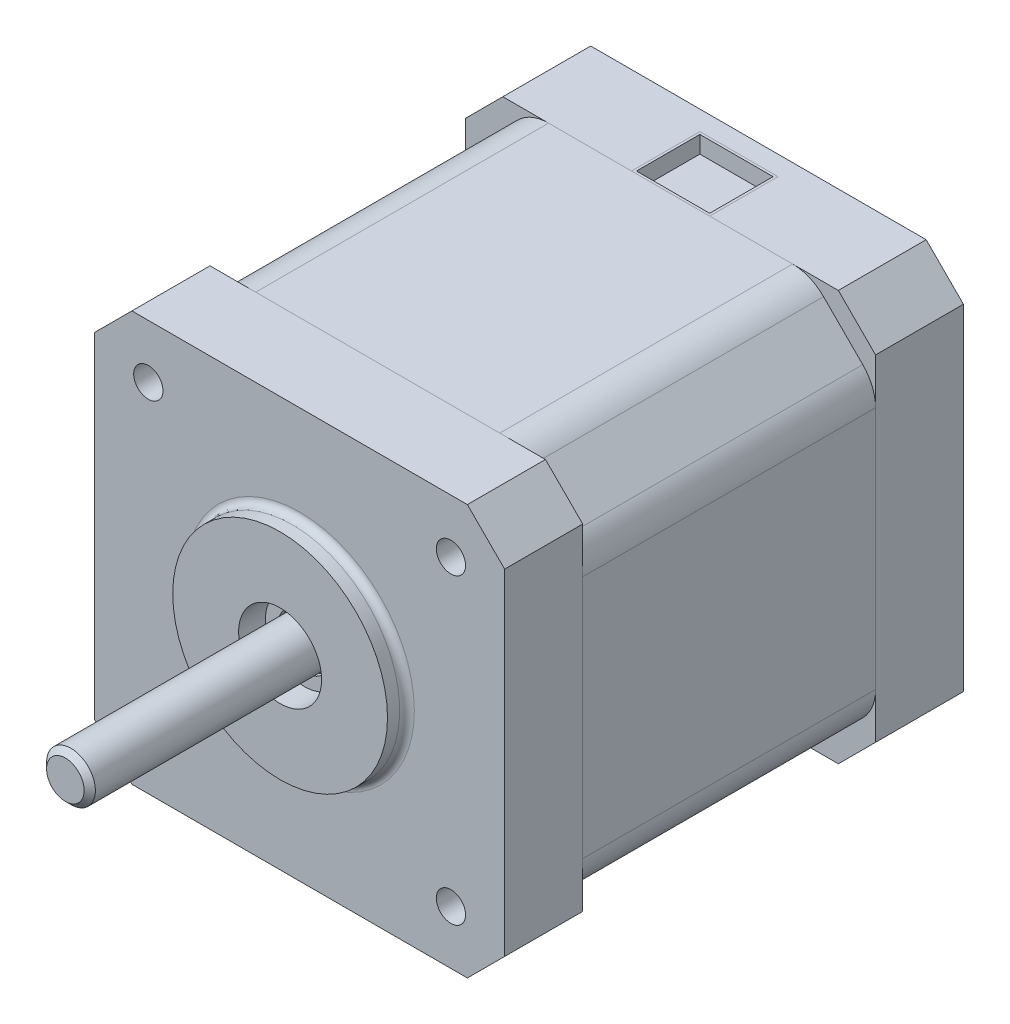
from build123d import *

# Parameters (mm, degrees)
BOSS_EXTRUDE1_DEPTH = 8
BOSS_EXTRUDE2_DEPTH = 30
BOSS_EXTRUDE3_DEPTH = 9
SKETCH5_R           = 1.5
CUT_EXTRUDE1_DEPTH  = 4.5
SKETCH6_R           = 11
BOSS_EXTRUDE4_DEPTH = 2
SKETCH9_R           = 4.25
CUT_EXTRUDE2_DEPTH  = 3
SKETCH8_R           = 2.5
BOSS_EXTRUDE5_DEPTH = 25
SKETCH11_R          = 4
SKETCH11_R_2        = 2.75
BOSS_EXTRUDE6_DEPTH = 0.5
FILLET1_R           = 0.75
SKETCH13_W          = 8
SKETCH13_H          = 7
CUT_EXTRUDE3_DEPTH  = 2
SKETCH14_W          = 8
SKETCH14_H          = 7
BOSS_EXTRUDE7_DEPTH = 0.25
SKETCH15_W          = 8
SKETCH15_H          = 7
SKETCH15_W_2        = 7.5
SKETCH15_H_2        = 6.5
BOSS_EXTRUDE8_DEPTH = 1.75


with BuildPart() as part:
    # Sketch1 → Boss-Extrude1 (new body)
    with BuildSketch(Plane.XY):
        Polygon((17.183766184, 21), (-17.183766184, 21), (-21, 17.183766184), (-21, -17.183766184), (-17.183766184, -21), (17.183766184, -21), (21, -17.183766184), (21, 17.183766184), align=None)
    extrude(amount=-BOSS_EXTRUDE1_DEPTH)

    # Sketch5 → Cut-Extrude1 (cut)
    with BuildSketch(Plane.XY):
        with Locations((-15.5, 15.5)):
            Circle(SKETCH5_R)
        with Locations((15.5, 15.5)):
            Circle(SKETCH5_R)
        with Locations((15.5, -15.5)):
            Circle(SKETCH5_R)
        with Locations((-15.5, -15.5)):
            Circle(SKETCH5_R)
    extrude(amount=-CUT_EXTRUDE1_DEPTH, mode=Mode.SUBTRACT)

    # Sketch6 → Boss-Extrude4 (add)
    with BuildSketch(Plane.XY):
        Circle(SKETCH6_R)
    extrude(amount=BOSS_EXTRUDE4_DEPTH)

    # Sketch9 → Cut-Extrude2 (cut)
    with BuildSketch(Plane.XY.offset(2)):
        Circle(SKETCH9_R)
    extrude(amount=-CUT_EXTRUDE2_DEPTH, mode=Mode.SUBTRACT)

    # Sketch11 → Boss-Extrude6 (add)
    with BuildSketch(Plane.XY.offset(-1)):
        Circle(SKETCH11_R)
        Circle(SKETCH11_R_2, mode=Mode.SUBTRACT)
    extrude(amount=BOSS_EXTRUDE6_DEPTH)

    # Fillet1
    fillet1_edges = [part.edges().sort_by_distance(p)[0] for p in [
        (-11, 0, 0),
    ]]
    fillet(fillet1_edges, radius=FILLET1_R)


with BuildPart() as body_2:
    # Sketch3 → Boss-Extrude2 (new body)
    with BuildSketch(Plane(origin=(0, 0, -8), x_dir=(-1, 0, 0), z_dir=(0, 0, -1))):
        with BuildLine():
            Line((-19.68807717, 15.66726189), (-15.66726189, 19.68807717))
            ThreePointArc((-15.66726189, 19.68807717), (-14.214109783, 20.659042365), (-12.5, 21))
            Line((-12.5, 21), (12.5, 21))
            ThreePointArc((12.5, 21), (14.214109783, 20.659042365), (15.66726189, 19.68807717))
            Line((15.66726189, 19.68807717), (19.68807717, 15.66726189))
            ThreePointArc((19.68807717, 15.66726189), (20.659042365, 14.214109783), (21, 12.5))
            Line((21, 12.5), (21, -12.5))
            ThreePointArc((21, -12.5), (20.659042365, -14.214109783), (19.68807717, -15.66726189))
            Line((19.68807717, -15.66726189), (15.66726189, -19.68807717))
            ThreePointArc((15.66726189, -19.68807717), (14.214109783, -20.659042365), (12.5, -21))
            Line((12.5, -21), (-12.5, -21))
            ThreePointArc((-12.5, -21), (-14.214109783, -20.659042365), (-15.66726189, -19.68807717))
            Line((-15.66726189, -19.68807717), (-19.68807717, -15.66726189))
            ThreePointArc((-19.68807717, -15.66726189), (-20.659042365, -14.214109783), (-21, -12.5))
            Line((-21, -12.5), (-21, 12.5))
            ThreePointArc((-21, 12.5), (-20.659042365, 14.214109783), (-19.68807717, 15.66726189))
        make_face()
    extrude(amount=BOSS_EXTRUDE2_DEPTH)


with BuildPart() as body_3:
    # Sketch4 → Boss-Extrude3 (new body)
    with BuildSketch(Plane(origin=(0, 0, -38), x_dir=(-1, 0, 0), z_dir=(0, 0, -1))):
        Polygon((-17.183766184, 21), (-21, 17.183766184), (-21, -17.183766184), (-17.183766184, -21), (17.183766184, -21), (21, -17.183766184), (21, 17.183766184), (17.183766184, 21), align=None)
    extrude(amount=BOSS_EXTRUDE3_DEPTH)

    # Sketch13 → Cut-Extrude3 (cut)
    with BuildSketch(Plane(origin=(0, 21, 0), x_dir=(1, 0, 0), z_dir=(0, 1, 0))):
        with Locations((0, 41.5)):
            Rectangle(SKETCH13_W, SKETCH13_H)
    extrude(amount=-CUT_EXTRUDE3_DEPTH, mode=Mode.SUBTRACT)


with BuildPart() as body_4:
    # Sketch8 → Boss-Extrude5 (new body)
    with BuildSketch(Plane.XY.offset(-1)):
        Circle(SKETCH8_R)
    extrude(amount=BOSS_EXTRUDE5_DEPTH)

    # Sketch12 → Cut-Revolve1 (revolve, cut)
    with BuildSketch(Plane(origin=(0, 0, 0), x_dir=(0, 0, -1), z_dir=(1, 0, 0))):
        Polygon((-24, 1.925), (-23.425, 2.5), (-24, 2.5), align=None)
    revolve(axis=Axis((0, 0, 24), (0, 0, -1)), mode=Mode.SUBTRACT)


with BuildPart() as body_5:
    # Sketch14 → Boss-Extrude7 (new body)
    with BuildSketch(Plane(origin=(0, 19, 0), x_dir=(1, 0, 0), z_dir=(0, 1, 0))):
        with Locations((0, 41.5)):
            Rectangle(SKETCH14_W, SKETCH14_H)
    extrude(amount=BOSS_EXTRUDE7_DEPTH)

    # Sketch15 → Boss-Extrude8 (add)
    with BuildSketch(Plane(origin=(0, 19.25, 0), x_dir=(1, 0, 0), z_dir=(0, 1, 0))):
        with Locations((0, 41.5)):
            Rectangle(SKETCH15_W, SKETCH15_H)
        with Locations((0, 41.5)):
            Rectangle(SKETCH15_W_2, SKETCH15_H_2, mode=Mode.SUBTRACT)
    extrude(amount=BOSS_EXTRUDE8_DEPTH)


solid = Compound([part.part, body_2.part, body_3.part, body_4.part, body_5.part])
